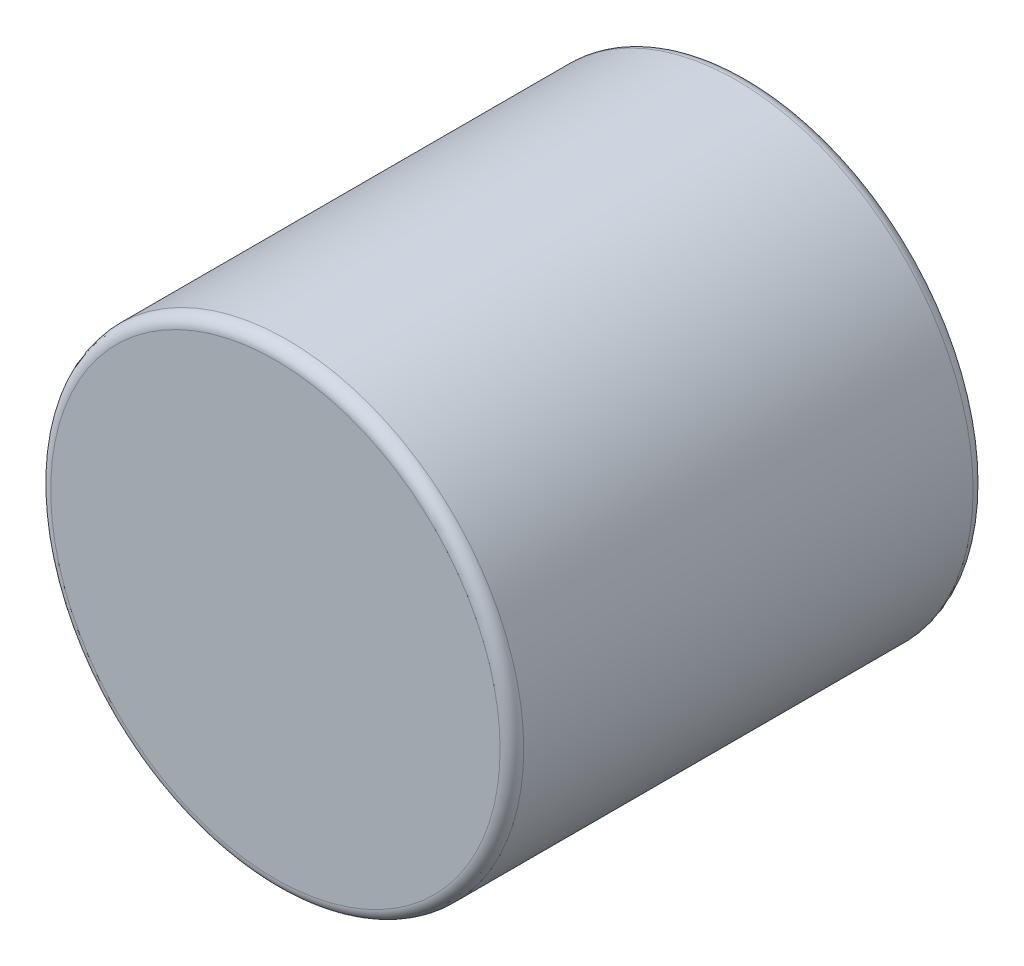
from build123d import *

# Parameters (mm, degrees)
SKETCH3_R                = 0.79375
BOSS_EXTRUDE1_DEPTH      = 0.79375
BOSS_EXTRUDE1_DEPTH_BACK = 0.79375
FILLET1_R                = 0.0396875


with BuildPart() as part:
    # Sketch3 → Boss-Extrude1 (new body, two sides)
    with BuildSketch(Plane.XY) as boss_extrude1_sk:
        Circle(SKETCH3_R)
    extrude(amount=BOSS_EXTRUDE1_DEPTH)
    extrude(boss_extrude1_sk.sketch, amount=-BOSS_EXTRUDE1_DEPTH_BACK)

    # Fillet1
    fillet1_edges = [part.edges().sort_by_distance(p)[0] for p in [
        (-0.79375, 0, -0.79375),
        (-0.79375, 0, 0.79375),
    ]]
    fillet(fillet1_edges, radius=FILLET1_R)


solid = part.part
